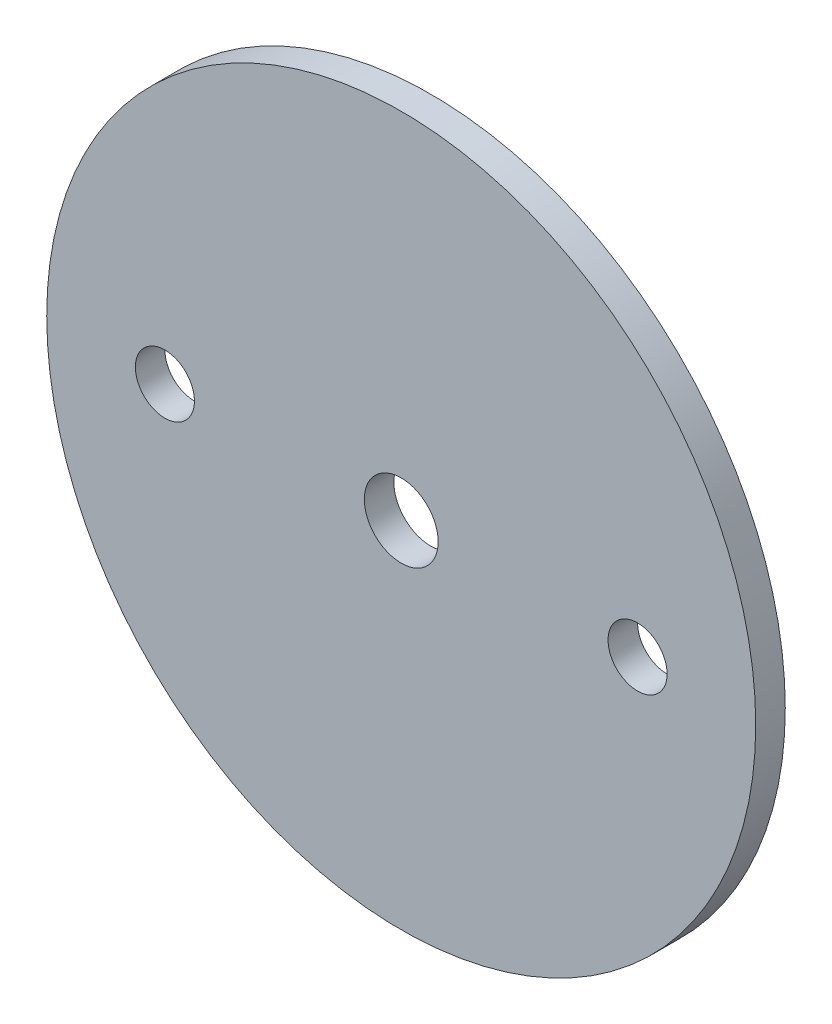
from build123d import *

# Parameters (mm, degrees)
SKETCH1_R                          = 38.1
BOSS_EXTRUDE1_DEPTH                = 1.5875
F_1_4_0_25_DIAMETER_HOLE1_D        = 6.35
F_5_16_0_3125_DIAMETER_HOLE1_D     = 7.9375
F_5_16_0_3125_DIAMETER_HOLE1_DEPTH = 3.302


with BuildPart() as part:
    # Sketch1 → Boss-Extrude1 (new body, symmetric)
    with BuildSketch(Plane.XY):
        Circle(SKETCH1_R)
    extrude(amount=BOSS_EXTRUDE1_DEPTH, both=True)

    # 1/4 (0.25) Diameter Hole1 (through all)
    with Locations(Plane.XY.offset(1.5875)):
        with Locations((-25.4, 0), (25.4, 0)):
            Hole(F_1_4_0_25_DIAMETER_HOLE1_D / 2)

    # 5/16 (0.3125) Diameter Hole1
    with Locations(Plane.XY.offset(1.5875)):
        with Locations((0, 0)):
            Hole(F_5_16_0_3125_DIAMETER_HOLE1_D / 2, depth=F_5_16_0_3125_DIAMETER_HOLE1_DEPTH)


solid = part.part
